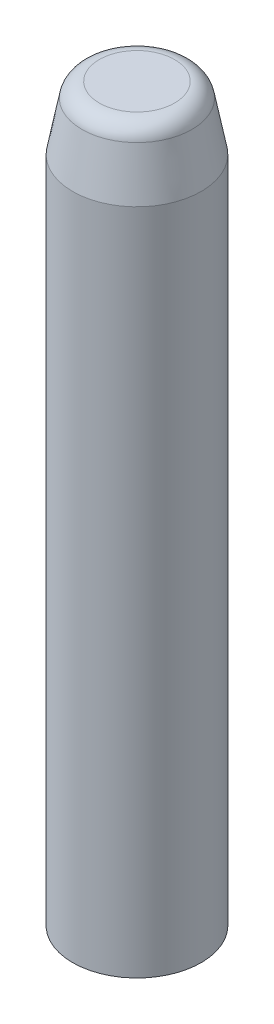
from build123d import *

# Parameters (mm, degrees)
SKETCH1_R           = 6.4
SKETCH1_R_2         = 3
BOSS_EXTRUDE2_DEPTH = 65
SKETCH4_R           = 0.5
CUT_EXTRUDE1_DEPTH  = 7.4


with BuildPart() as part:
    # Sketch1 → Boss-Extrude2 (new body)
    with BuildSketch(Plane(origin=(0, 0, 0), x_dir=(1, 0, 0), z_dir=(0, 1, 0))):
        Circle(SKETCH1_R)
        Circle(SKETCH1_R_2, mode=Mode.SUBTRACT)
    extrude(amount=BOSS_EXTRUDE2_DEPTH)

    # Sketch2 → Revolve2 (revolve)
    with BuildSketch(Plane.XY):
        with BuildLine():
            Line((-6.4, 65), (-6.4, 66.5))
            Line((-6.4, 66.5), (-5.470962631, 71.377446189))
            ThreePointArc((-5.470962631, 71.377446189), (-4.867546878, 72.39824531), (-3.751870139, 72.8))
            Line((-3.751870139, 72.8), (0, 72.8))
            Line((0, 72.8), (0, 65))
            Line((0, 65), (-6.4, 65))
        make_face()
    revolve(axis=Axis((0, 72.8, 0), (0, -1, 0)))

    # Sketch4 → Cut-Extrude1 (cut, through all)
    with BuildSketch(Plane.XY):
        with Locations((0, 70)):
            Circle(SKETCH4_R)
    extrude(amount=-CUT_EXTRUDE1_DEPTH, mode=Mode.SUBTRACT)


solid = part.part
